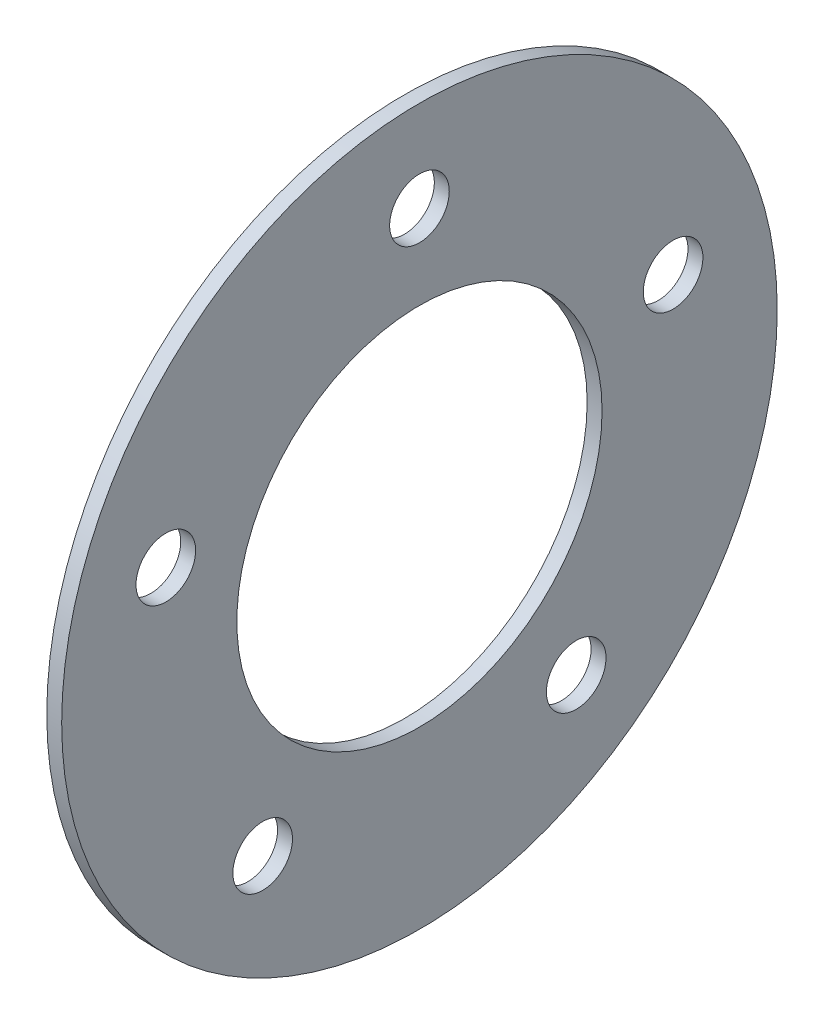
from build123d import *

# Parameters (mm, degrees)
SKETCH1_R           = 76.2
SKETCH1_R_2         = 38.89375
BOSS_EXTRUDE1_DEPTH = 1.5875
SKETCH3_R           = 6.35
CUT_EXTRUDE1_DEPTH  = 108.809835474
CIRPATTERN1_COUNT   = 5


with BuildPart() as part:
    # Sketch1 → Boss-Extrude1 (new, symmetric)
    with BuildSketch(Plane(origin=(0, 0, 0), x_dir=(0, 0, -1), z_dir=(1, 0, 0))):
        Circle(SKETCH1_R)
        Circle(SKETCH1_R_2, mode=Mode.SUBTRACT)
    extrude(amount=BOSS_EXTRUDE1_DEPTH, both=True)

    # Sketch3 → Cut-Extrude1 (cut, through all)
    with BuildSketch(Plane(origin=(1.5875, 0, 0), x_dir=(0, 0, -1), z_dir=(1, 0, 0))):
        with Locations((0, 56.79948)):
            Circle(SKETCH3_R)
    cut_extrude1 = extrude(amount=-CUT_EXTRUDE1_DEPTH, mode=Mode.SUBTRACT)

    # CirPattern1: Cut-Extrude1 ×5 about axis
    cirpattern1_axis = Axis((-1.74625, 0, 0), (1, 0, 0))
    for i in range(1, CIRPATTERN1_COUNT):
        add(cut_extrude1.rotate(cirpattern1_axis, i * 360 / CIRPATTERN1_COUNT), mode=Mode.SUBTRACT)


solid = part.part
